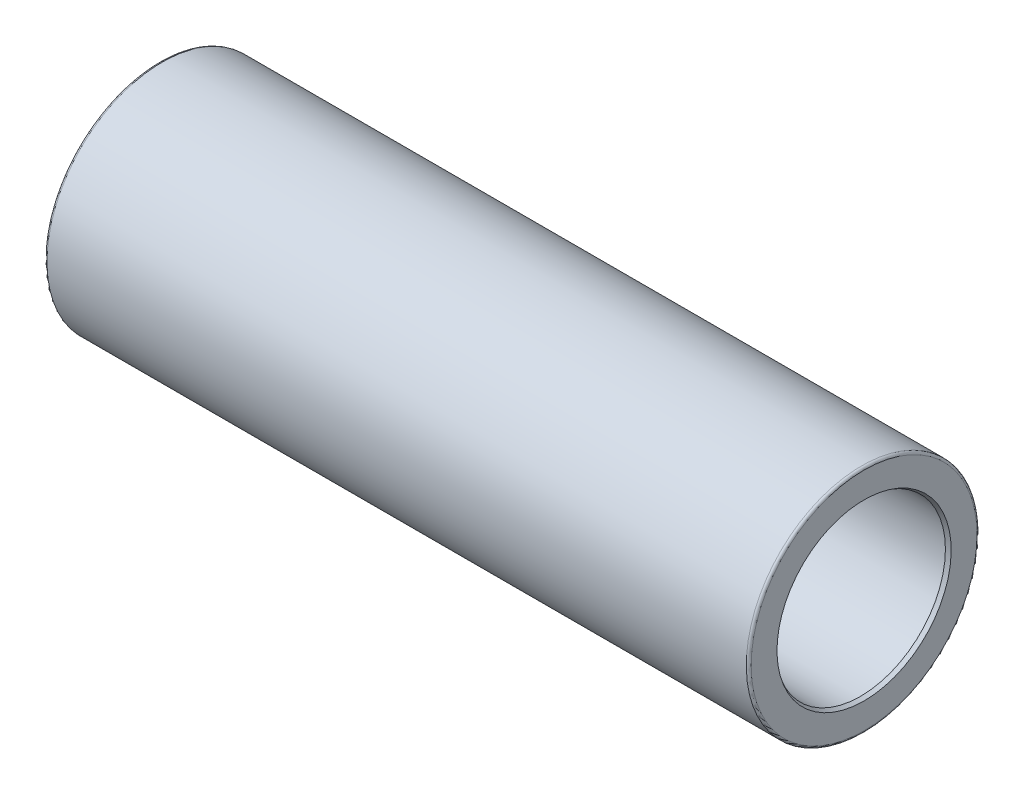
from build123d import *


with BuildPart() as part:
    # Sketch1 → Base-Revolve (revolve)
    with BuildSketch(Plane.XY):
        with BuildLine():
            Line((-145, 35), (-145, 46.5))
            ThreePointArc((-145, 46.5), (-144.707106781, 47.207106781), (-144, 47.5))
            Line((-144, 47.5), (144, 47.5))
            ThreePointArc((144, 47.5), (144.707106781, 47.207106781), (145, 46.5))
            Line((145, 46.5), (145, 35))
            Line((145, 35), (65, 35))
            Line((65, 35), (58.296999614, 37.439692621))
            ThreePointArc((58.296999614, 37.439692621), (58.128627648, 37.484807753), (57.954979471, 37.5))
            Line((57.954979471, 37.5), (-57.954979471, 37.5))
            ThreePointArc((-57.954979471, 37.5), (-58.128627648, 37.484807753), (-58.296999614, 37.439692621))
            Line((-58.296999614, 37.439692621), (-65, 35))
            Line((-65, 35), (-145, 35))
        make_face()
    revolve(axis=Axis((-145, 0, 0), (1, 0, 0)))

    # Sketch5 → 2.5 x 30 gr reifning (revolve, cut)
    with BuildSketch(Plane.XY):
        Polygon((145, 35.866025404), (143.5, 35), (145, 35), align=None)
        Polygon((-145, 35), (-145, 35.866025404), (-143.5, 35), align=None)
    revolve(axis=Axis((0, 0, 0), (1, 0, 0)), mode=Mode.SUBTRACT)


solid = part.part
